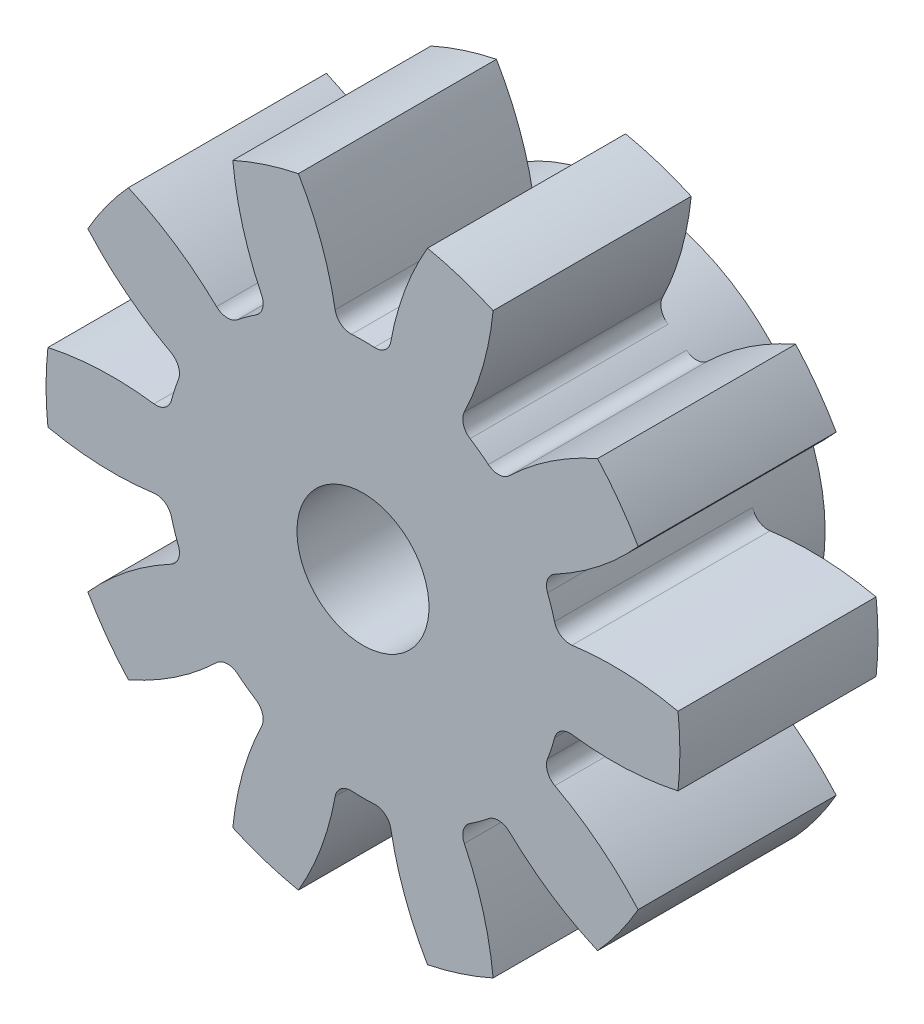
from build123d import *

# Parameters (mm, degrees)
SKETCH1_R                = 12
BOSS_EXTRUDE1_DEPTH      = 212.5
CUT_EXTRUDE1_DEPTH       = 213.5
FILLET1_R                = 0.6
FILLET2_R                = 0.6
CIRPATTERN2_COUNT        = 10
FILLET1_OF_CIRPATTERN2_R = 0.6
FILLET2_OF_CIRPATTERN2_R = 0.6
SKETCH4_R                = 7.5
SKETCH4_R_2              = 2.5
BOSS_EXTRUDE2_DEPTH      = 2.5
SKETCH5_R                = 3
CUT_EXTRUDE2_DEPTH       = 3.5
CUT_EXTRUDE2_DEPTH_BACK  = 32
SKETCH6_R                = 7.5
BOSS_EXTRUDE3_DEPTH      = 6
CUT_EXTRUDE3_START       = -423.5
SKETCH7_R                = 12
CUT_EXTRUDE3_DEPTH       = 423.5
SKETCH8_R                = 7.5
SKETCH8_R_2              = 1.65
BOSS_EXTRUDE4_DEPTH      = 10
SKETCH9_R                = 2.5
CUT_EXTRUDE4_DEPTH       = 20.205882453


with BuildPart() as part:
    # Sketch1 → Boss-Extrude1 (new body, symmetric)
    with BuildSketch(Plane.XY):
        Circle(SKETCH1_R)
    extrude(amount=BOSS_EXTRUDE1_DEPTH, both=True)

    # Sketch2 → Cut-Extrude1 (cut, symmetric)
    with BuildSketch(Plane.XY):
        with BuildLine():
            ThreePointArc((-3.025362823, 12.643068448), (-1.674613805, 10.167523315), (-0.969059762, 7.437131381))
            ThreePointArc((-0.969059762, 7.437131381), (0, 7.5), (0.969059762, 7.437131381))
            ThreePointArc((0.969059762, 7.437131381), (1.674613805, 10.167523315), (3.025362823, 12.643068448))
            ThreePointArc((3.025362823, 12.643068448), (0, 13), (-3.025362823, 12.643068448))
        make_face()
    cut_extrude1 = extrude(amount=CUT_EXTRUDE1_DEPTH, both=True, mode=Mode.SUBTRACT)

    # Fillet1
    fillet1_edges = [part.edges().sort_by_distance(p)[0] for p in [
        (-0.969059762, 7.437131381, 0),
    ]]
    fillet(fillet1_edges, radius=FILLET1_R)

    # Fillet2
    fillet2_edges = [part.edges().sort_by_distance(p)[0] for p in [
        (0.969059762, 7.437131381, 0),
    ]]
    fillet(fillet2_edges, radius=FILLET2_R)

    # CirPattern2: Cut-Extrude1 ×10 about axis
    cirpattern2_axis = Axis((0, 0, 0), (0, 0, 1))
    for i in range(1, CIRPATTERN2_COUNT):
        add(cut_extrude1.rotate(cirpattern2_axis, i * 360 / CIRPATTERN2_COUNT), mode=Mode.SUBTRACT)

    # Fillet1 of CirPattern2
    fillet1_of_cirpattern2_edges = [part.edges().sort_by_distance(p)[0] for p in [
        (-5.155421961, 5.44716664, 0),
        (-7.372588197, 1.376569385, 0),
        (-6.773676327, -3.219830588, 0),
        (-3.587450329, -6.586364713, 0),
        (0.969059762, -7.437131381, 0),
        (5.155421961, -5.44716664, 0),
        (7.372588197, -1.376569385, 0),
        (6.773676327, 3.219830588, 0),
        (3.587450329, 6.586364713, 0),
    ]]
    fillet(fillet1_of_cirpattern2_edges, radius=FILLET1_OF_CIRPATTERN2_R)

    # Fillet2 of CirPattern2
    fillet2_of_cirpattern2_edges = [part.edges().sort_by_distance(p)[0] for p in [
        (-3.587450329, 6.586364713, 0),
        (-6.773676327, 3.219830588, 0),
        (-7.372588197, -1.376569385, 0),
        (-5.155421961, -5.44716664, 0),
        (-0.969059762, -7.437131381, 0),
        (3.587450329, -6.586364713, 0),
        (6.773676327, -3.219830588, 0),
        (7.372588197, 1.376569385, 0),
        (5.155421961, 5.44716664, 0),
    ]]
    fillet(fillet2_of_cirpattern2_edges, radius=FILLET2_OF_CIRPATTERN2_R)

    # Sketch4 → Boss-Extrude2 (add, symmetric)
    with BuildSketch(Plane(origin=(0, 0, -212.5), x_dir=(-1, 0, 0), z_dir=(0, 0, -1))):
        Circle(SKETCH4_R)
        Circle(SKETCH4_R_2, mode=Mode.SUBTRACT)
    extrude(amount=BOSS_EXTRUDE2_DEPTH, both=True)

    # Sketch5 → Cut-Extrude2 (cut, two sides)
    with BuildSketch(Plane(origin=(0, 0, -212.5), x_dir=(-1, 0, 0), z_dir=(0, 0, -1))) as cut_extrude2_sk:
        Circle(SKETCH5_R)
    extrude(amount=CUT_EXTRUDE2_DEPTH, mode=Mode.SUBTRACT)
    extrude(cut_extrude2_sk.sketch, amount=-CUT_EXTRUDE2_DEPTH_BACK, mode=Mode.SUBTRACT)

    # Sketch6 → Boss-Extrude3 (add, symmetric)
    with BuildSketch(Plane.XY.offset(212.5)):
        Circle(SKETCH6_R)
    extrude(amount=BOSS_EXTRUDE3_DEPTH, both=True)

    # Sketch7 → Cut-Extrude3 (cut)
    with BuildSketch(Plane.XY.offset(218.5).offset(CUT_EXTRUDE3_START)):
        Circle(SKETCH7_R)
    extrude(amount=CUT_EXTRUDE3_DEPTH, mode=Mode.SUBTRACT)

    # Sketch8 → Boss-Extrude4 (add)
    with BuildSketch(Plane(origin=(0, 0, -215), x_dir=(-1, 0, 0), z_dir=(0, 0, -1))):
        Circle(SKETCH8_R)
        Circle(SKETCH8_R_2, mode=Mode.SUBTRACT)
    extrude(amount=-BOSS_EXTRUDE4_DEPTH)

    # Sketch9 → Cut-Extrude4 (cut, through all)
    with BuildSketch(Plane(origin=(0, 0, -224.205882353), x_dir=(-1, 0, 0), z_dir=(0, 0, -1))):
        Circle(SKETCH9_R)
    extrude(amount=-CUT_EXTRUDE4_DEPTH, mode=Mode.SUBTRACT)


solid = part.part
